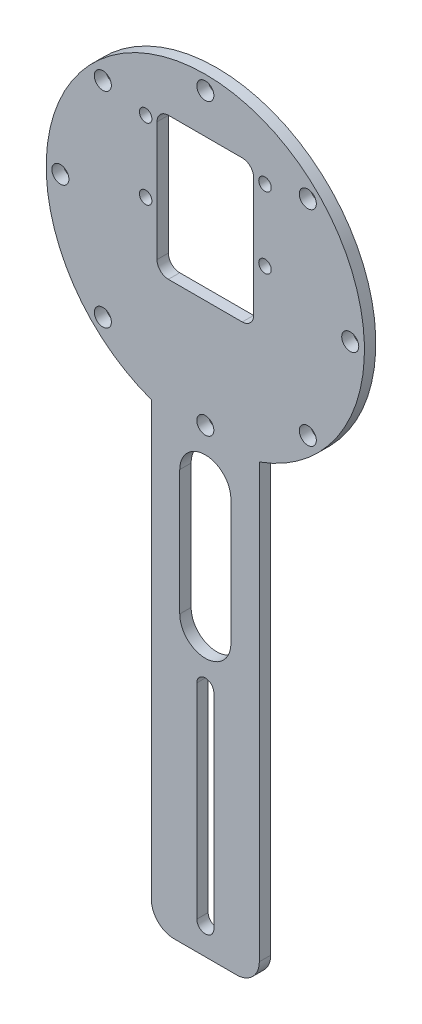
from build123d import *

# Parameters (mm, degrees)
ESQUISSE1_R             = 1.1
ESQUISSE1_R_2           = 1.5
ESQUISSE1_W             = 17
ESQUISSE1_H             = 25
BOSS_EXTRU_1_DEPTH      = 2
CONG_1_R                = 2
ENL_V_MAT_EXTRU_1_DEPTH = 2
CONG_2_R                = 4


with BuildPart() as part:
    # Esquisse1 → Boss.-Extru.1 (new body)
    with BuildSketch(Plane.XY):
        with BuildLine():
            Line((9.5, 0), (-9.5, 0))
            Line((-9.5, 0), (-9.5, 80.160865618))
            ThreePointArc((-9.5, 80.160865618), (0, 134.5), (9.5, 80.160865618))
            Line((9.5, 80.160865618), (9.5, 0))
        make_face()
        with Locations((-10.5, 123)):
            Circle(ESQUISSE1_R, mode=Mode.SUBTRACT)
        with Locations((-10.5, 110.5)):
            Circle(ESQUISSE1_R, mode=Mode.SUBTRACT)
        with Locations((10.5, 110.5)):
            Circle(ESQUISSE1_R, mode=Mode.SUBTRACT)
        with Locations((10.5, 123)):
            Circle(ESQUISSE1_R, mode=Mode.SUBTRACT)
        with Locations((0, 132)):
            Circle(ESQUISSE1_R_2, mode=Mode.SUBTRACT)
        with Locations((18.03122292, 124.53122292)):
            Circle(ESQUISSE1_R_2, mode=Mode.SUBTRACT)
        with Locations((25.5, 106.5)):
            Circle(ESQUISSE1_R_2, mode=Mode.SUBTRACT)
        with Locations((18.03122292, 88.46877708)):
            Circle(ESQUISSE1_R_2, mode=Mode.SUBTRACT)
        with Locations((0, 81)):
            Circle(ESQUISSE1_R_2, mode=Mode.SUBTRACT)
        with Locations((-18.03122292, 88.46877708)):
            Circle(ESQUISSE1_R_2, mode=Mode.SUBTRACT)
        with Locations((-25.5, 106.5)):
            Circle(ESQUISSE1_R_2, mode=Mode.SUBTRACT)
        with Locations((-18.03122292, 124.53122292)):
            Circle(ESQUISSE1_R_2, mode=Mode.SUBTRACT)
        with Locations((0, 112.5)):
            Rectangle(ESQUISSE1_W, ESQUISSE1_H, mode=Mode.SUBTRACT)
    extrude(amount=BOSS_EXTRU_1_DEPTH)

    # Congé1
    cong_1_edges = [part.edges().sort_by_distance(p)[0] for p in [
        (-8.5, 125, 1),
        (-8.5, 100, 1),
        (8.5, 100, 1),
        (8.5, 125, 1),
    ]]
    fillet(cong_1_edges, radius=CONG_1_R)

    # Esquisse2 → Enlèv. mat.-Extru.1 (cut)
    with BuildSketch(Plane.XY.offset(2)):
        with BuildLine():
            Line((4.5, 72), (4.5, 50))
            ThreePointArc((4.5, 50), (0, 45.5), (-4.5, 50))
            Line((-4.5, 50), (-4.5, 72))
            ThreePointArc((-4.5, 72), (0, 76.5), (4.5, 72))
        make_face()
        with BuildLine():
            Line((1.5, 41), (1.5, 5))
            ThreePointArc((1.5, 5), (0, 3.5), (-1.5, 5))
            Line((-1.5, 5), (-1.5, 41))
            ThreePointArc((-1.5, 41), (0, 42.5), (1.5, 41))
        make_face()
    extrude(amount=-ENL_V_MAT_EXTRU_1_DEPTH, mode=Mode.SUBTRACT)

    # Congé2
    cong_2_edges = [part.edges().sort_by_distance(p)[0] for p in [
        (9.5, 0, 1),
        (-9.5, 0, 1),
    ]]
    fillet(cong_2_edges, radius=CONG_2_R)


solid = part.part
